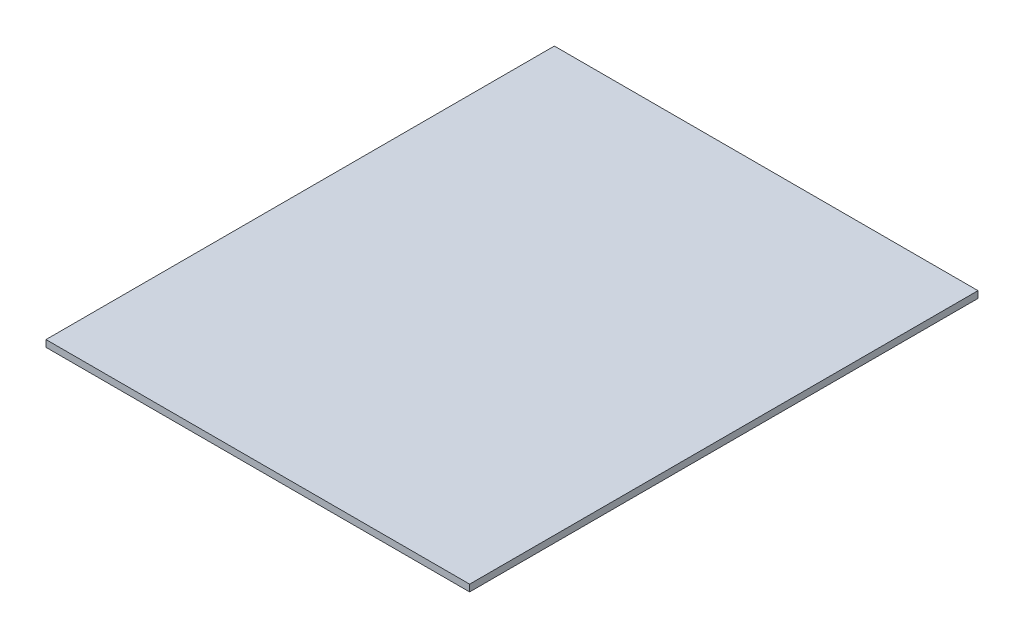
from build123d import *

# Parameters (mm, degrees)
SKETCH1_W           = 317.5
SKETCH1_H           = 381
BOSS_EXTRUDE1_DEPTH = 5.08


with BuildPart() as part:
    # Sketch1 → Boss-Extrude1 (new body)
    with BuildSketch(Plane(origin=(0, 0, 0), x_dir=(1, 0, 0), z_dir=(0, 1, 0))):
        Rectangle(SKETCH1_W, SKETCH1_H)
    extrude(amount=BOSS_EXTRUDE1_DEPTH)


solid = part.part
